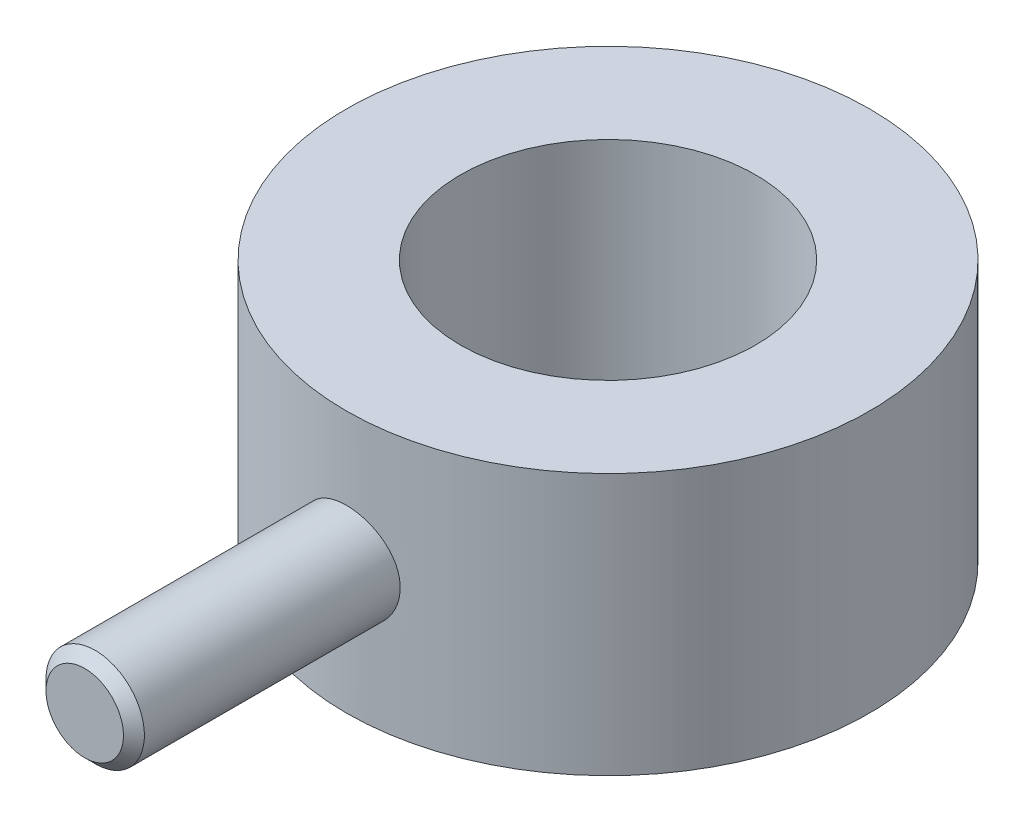
from build123d import *

# Parameters (mm, degrees)
SKETCH1_R           = 6.35
SKETCH1_R_2         = 3.5814
EXTRUDE1_DEPTH      = 3.175
EXTRUDE1_DEPTH_BACK = 3.175
SKETCH4_W           = 1.1938
SKETCH4_H           = 7.9248
CHAMFER1_SIZE       = 0.254


with BuildPart() as part:
    # Sketch1 → Extrude1 (new, two sides)
    with BuildSketch(Plane(origin=(0, 0, 0), x_dir=(1, 0, 0), z_dir=(0, 1, 0))) as extrude1_sk:
        with Locations(Location((0, 0, 0), (0, 0, 270))):
            Circle(SKETCH1_R)
        with Locations(Location((0, 0, 0), (0, 0, 270))):
            Circle(SKETCH1_R_2, mode=Mode.SUBTRACT)
    extrude(amount=EXTRUDE1_DEPTH)
    extrude(extrude1_sk.sketch, amount=-EXTRUDE1_DEPTH_BACK)

    # Sketch4 → Revolve1 (revolve)
    with BuildSketch(Plane(origin=(0, 0, 0), x_dir=(1, 0, 0), z_dir=(0, 1, 0)), mode=Mode.PRIVATE) as revolve1_sk:
        with Locations((0.5969, -8.7376)):
            Rectangle(SKETCH4_W, SKETCH4_H)
    revolve(revolve1_sk.sketch.rotate(Axis((0, 0, 4.7752), (0, 0, 1)), 180), axis=Axis((0, 0, 4.7752), (0, 0, 1)))

    # Chamfer1
    chamfer1_edges = [part.edges().sort_by_distance(p)[0] for p in [
        (1.1938, 0, 12.7),
    ]]
    chamfer(chamfer1_edges, length=CHAMFER1_SIZE)


solid = part.part
